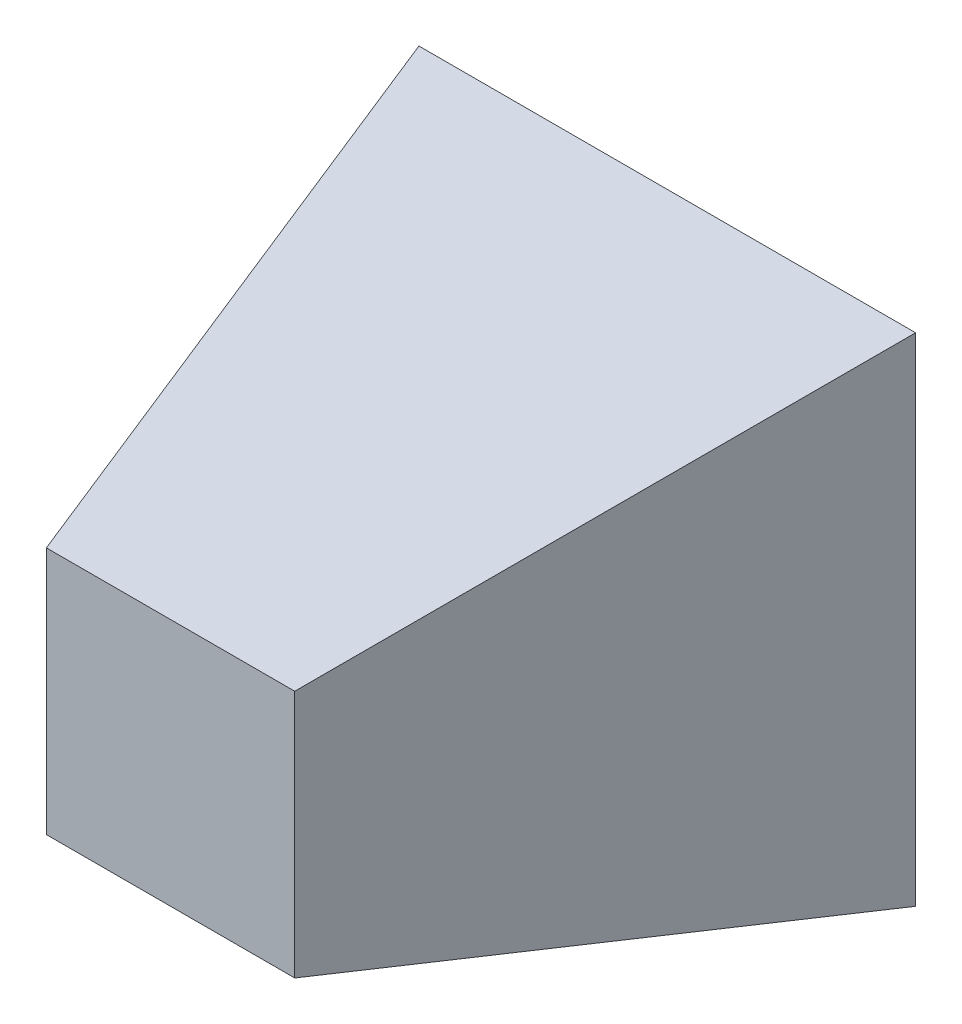
from build123d import *

# Parameters (mm, degrees)
SKETCH1_W = 100
SKETCH1_H = 100
SKETCH2_W = 50
SKETCH2_H = 50


with BuildPart() as part:
    # Sketch1 → Loft1 section 0
    with BuildSketch(Plane.XY):
        Rectangle(SKETCH1_W, SKETCH1_H)
    # Sketch2 → Loft1 section 1
    with BuildSketch(Plane.XY.offset(100)):
        Rectangle(SKETCH2_W, SKETCH2_H)
    loft()


solid = part.part
